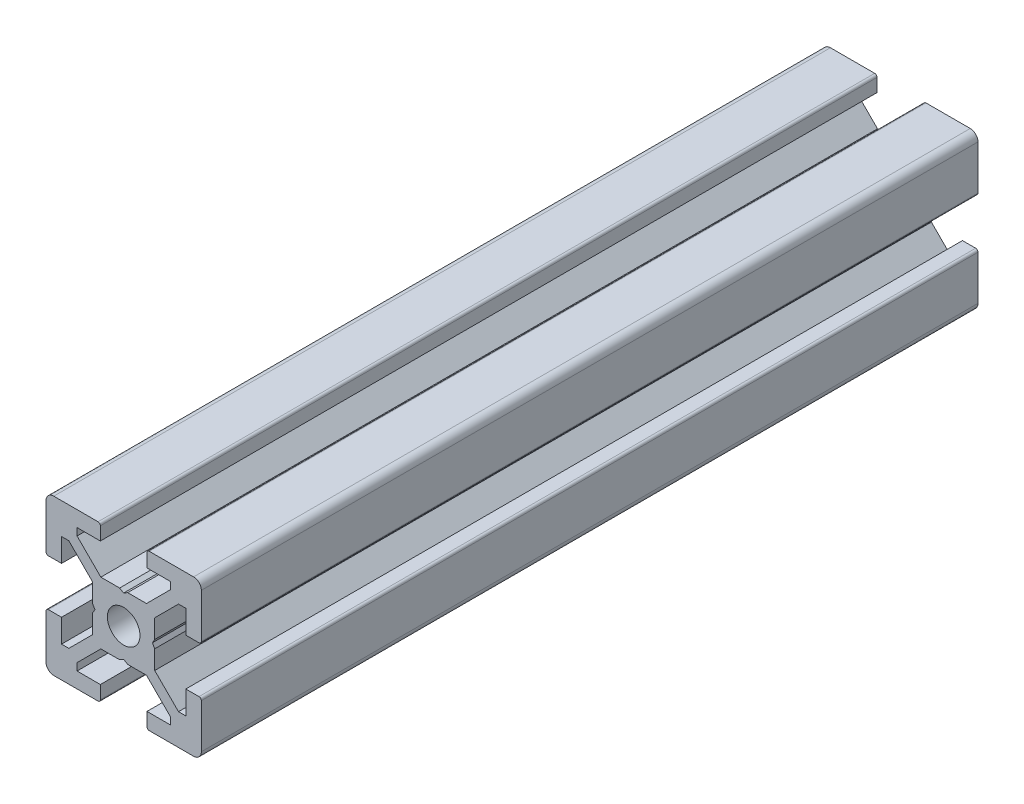
from build123d import *

# Parameters (mm, degrees)
BOSS_EXTRUDE1_DEPTH = 100
SKETCH2_W           = 100
SKETCH2_H           = 2.1
SKETCH4_R           = 2.5
CUT_EXTRUDE1_DEPTH  = 8


with BuildPart() as part:
    # Sketch1 → Boss-Extrude1 (new body)
    with BuildSketch(Plane.XY):
        with BuildLine():
            Line((-10, 9), (-10, 3.29999995))
            ThreePointArc((-10, 3.29999995), (-9.912132049, 3.087867916), (-9.7, 3))
            Line((-9.7, 3), (-8, 3))
            Line((-8, 3), (-8, 6))
            Line((-8, 6), (-7.060677, 6))
            Line((-7.060677, 6), (-4, 2.93932965))
            Line((-4, 2.93932965), (-4, 0.519615242))
            Line((-4, 0.519615242), (-3.699996283, -6.437e-06))
            Line((-3.699996283, -6.437e-06), (-4, -0.519628117))
            Line((-4, -0.519628117), (-4, -2.93933725))
            Line((-4, -2.93933725), (-7.0606695, -6))
            Line((-7.0606695, -6), (-8, -6))
            Line((-8, -6), (-8, -3))
            Line((-8, -3), (-9.7, -3))
            ThreePointArc((-9.7, -3), (-9.912132049, -3.087867916), (-10, -3.29999995))
            Line((-10, -3.29999995), (-10, -9))
            ThreePointArc((-10, -9), (-9.707106781, -9.707106781), (-9, -10))
            Line((-9, -10), (-3.29999995, -10))
            ThreePointArc((-3.29999995, -10), (-3.087867916, -9.912132049), (-3, -9.7))
            Line((-3, -9.7), (-3, -8))
            Line((-3, -8), (-6, -8))
            Line((-6, -8), (-6, -7.0606515))
            Line((-6, -7.0606515), (-2.9393489, -4))
            Line((-2.9393489, -4), (-0.519615242, -4))
            Line((-0.519615242, -4), (6.437e-06, -3.699996283))
            Line((6.437e-06, -3.699996283), (0.519628117, -4))
            Line((0.519628117, -4), (2.9393227, -4))
            Line((2.9393227, -4), (6, -7.060677))
            Line((6, -7.060677), (6, -8))
            Line((6, -8), (3, -8))
            Line((3, -8), (3, -9.7))
            ThreePointArc((3, -9.7), (3.087867916, -9.912132049), (3.29999995, -10))
            Line((3.29999995, -10), (9, -10))
            ThreePointArc((9, -10), (9.707106781, -9.707106781), (10, -9))
            Line((10, -9), (10, -3.29999995))
            ThreePointArc((10, -3.29999995), (9.912132049, -3.087867916), (9.7, -3))
            Line((9.7, -3), (8, -3))
            Line((8, -3), (8, -6))
            Line((8, -6), (7.0606435, -6))
            Line((7.0606435, -6), (4, -2.9393482))
            Line((4, -2.9393482), (4, -0.519615242))
            Line((4, -0.519615242), (3.699996283, 6.437e-06))
            Line((3.699996283, 6.437e-06), (4, 0.519628117))
            Line((4, 0.519628117), (4, 2.9393401))
            Line((4, 2.9393401), (7.060651, 6))
            Line((7.060651, 6), (8, 6))
            Line((8, 6), (8, 3))
            Line((8, 3), (9.7, 3))
            ThreePointArc((9.7, 3), (9.912132049, 3.087867916), (10, 3.29999995))
            Line((10, 3.29999995), (10, 9))
            ThreePointArc((10, 9), (9.707106781, 9.707106781), (9, 10))
            Line((9, 10), (3.29999995, 10))
            ThreePointArc((3.29999995, 10), (3.087867916, 9.912132049), (3, 9.7))
            Line((3, 9.7), (3, 8))
            Line((3, 8), (6, 8))
            Line((6, 8), (6, 7.060669))
            Line((6, 7.060669), (2.9393308, 4))
            Line((2.9393308, 4), (0.519615242, 4))
            Line((0.519615242, 4), (-6.437e-06, 3.699996283))
            Line((-6.437e-06, 3.699996283), (-0.519628117, 4))
            Line((-0.519628117, 4), (-2.93935655, 4))
            Line((-2.93935655, 4), (-6, 7.0606435))
            Line((-6, 7.0606435), (-6, 8))
            Line((-6, 8), (-3, 8))
            Line((-3, 8), (-3, 9.7))
            ThreePointArc((-3, 9.7), (-3.087867966, 9.912132034), (-3.3, 10))
            Line((-3.3, 10), (-9, 10))
            ThreePointArc((-9, 10), (-9.707106781, 9.707106781), (-10, 9))
        make_face()
    extrude(amount=-BOSS_EXTRUDE1_DEPTH)

    # Sketch2 → Cut-Revolve1 (revolve, cut)
    with BuildSketch(Plane(origin=(0, 0, 0), x_dir=(0, 0, -1), z_dir=(1, 0, 0))):
        with Locations((50, 1.05)):
            Rectangle(SKETCH2_W, SKETCH2_H)
    revolve(axis=Axis((0, 0, -100), (0, 0, 1)), mode=Mode.SUBTRACT)

    # Sketch4 → Cut-Extrude1 (cut)
    with BuildSketch(Plane(origin=(4, 0, 0), x_dir=(0, 0, -1), z_dir=(1, 0, 0))):
        with Locations((10, 6.437e-06)):
            Circle(SKETCH4_R)
    extrude(amount=-CUT_EXTRUDE1_DEPTH, mode=Mode.SUBTRACT)


solid = part.part
